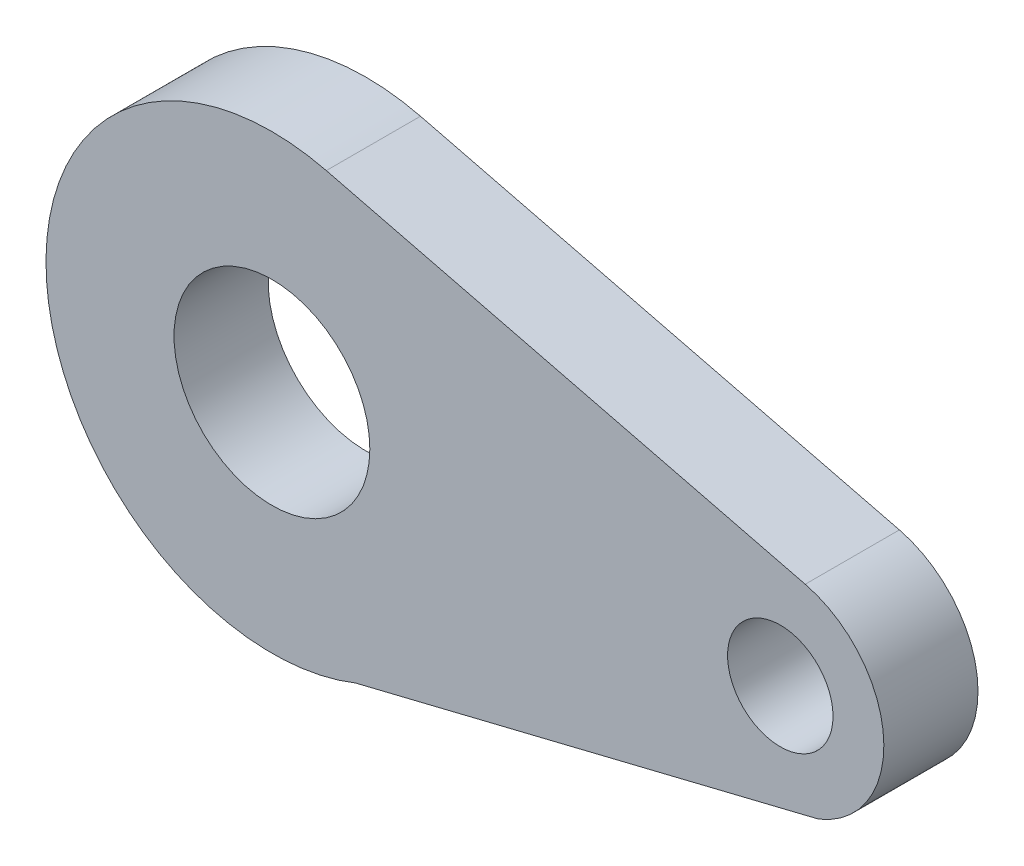
from build123d import *

# Parameters (mm, degrees)
SKETCH_1_R      = 2.6
SKETCH_1_R_2    = 1.4
EXTRUDE_1_DEPTH = 2.5


with BuildPart() as part:
    # 草圖1 → 填料-伸長1 (new body)
    with BuildSketch(Plane.XY):
        with BuildLine():
            Line((1.444444444, 5.823536747), (14.162037037, 2.669121009))
            ThreePointArc((14.162037037, 2.669121009), (16.24361838, 0.187238312), (14.518518519, -2.554431449))
            Line((14.518518519, -2.554431449), (2.222222222, -5.57330498))
            ThreePointArc((2.222222222, -5.57330498), (-5.986076465, -0.408519953), (1.444444444, 5.823536747))
        make_face()
        Circle(SKETCH_1_R, mode=Mode.SUBTRACT)
        with Locations((13.5, 0)):
            Circle(SKETCH_1_R_2, mode=Mode.SUBTRACT)
    extrude(amount=EXTRUDE_1_DEPTH)


solid = part.part
